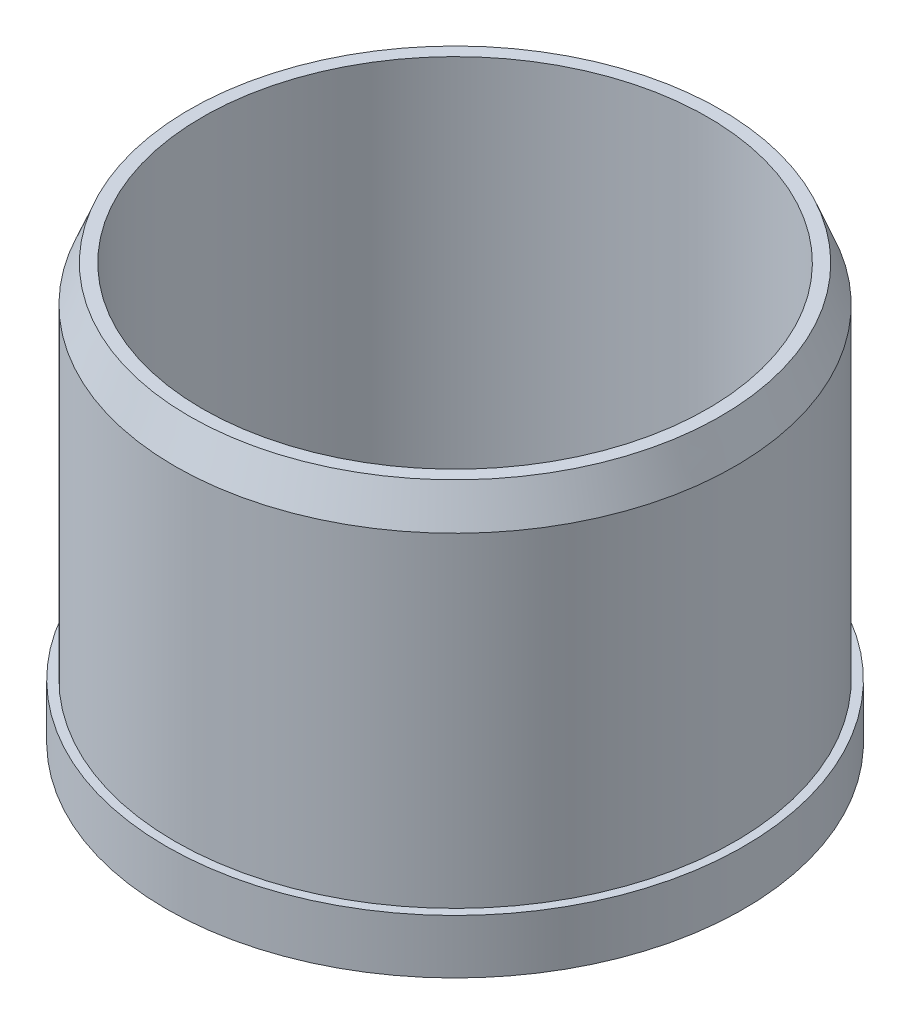
from build123d import *

# Parameters (mm, degrees)
SKETCH1_R           = 50.8
SKETCH1_R_2         = 6.5024
SKETCH1_R_3         = 12.7
BOSS_EXTRUDE1_DEPTH = 9.525
SKETCH2_R           = 49.276
SKETCH2_R_2         = 44.45
BOSS_EXTRUDE2_DEPTH = 63.5
SKETCH3_R           = 12.7
SKETCH3_R_2         = 6.5024
BOSS_EXTRUDE3_DEPTH = 15.875
CHAMFER1_SIZE       = 6.35
CHAMFER1_SIZE2      = 2.54
SKETCH4_R           = 12.7
SKETCH4_R_2         = 6.5024
BOSS_EXTRUDE4_DEPTH = 6.35
FILLET1_R           = 2.54


with BuildPart() as part:
    # Sketch1 → Boss-Extrude1 (new body)
    with BuildSketch(Plane(origin=(0, 0, 0), x_dir=(1, 0, 0), z_dir=(0, 1, 0))):
        Circle(SKETCH1_R)
        Circle(SKETCH1_R_2, mode=Mode.SUBTRACT)
        with Locations((0, 28.575)):
            Circle(SKETCH1_R_3, mode=Mode.SUBTRACT)
        with Locations((27.176439953, 8.830160614)):
            Circle(SKETCH1_R_3, mode=Mode.SUBTRACT)
        with Locations((16.795963584, -23.117660614)):
            Circle(SKETCH1_R_3, mode=Mode.SUBTRACT)
        with Locations((-16.795963584, -23.117660614)):
            Circle(SKETCH1_R_3, mode=Mode.SUBTRACT)
        with Locations((-27.176439953, 8.830160614)):
            Circle(SKETCH1_R_3, mode=Mode.SUBTRACT)
    extrude(amount=BOSS_EXTRUDE1_DEPTH)

    # Sketch2 → Boss-Extrude2 (add)
    with BuildSketch(Plane(origin=(0, 9.525, 0), x_dir=(1, 0, 0), z_dir=(0, 1, 0))):
        Circle(SKETCH2_R)
        Circle(SKETCH2_R_2, mode=Mode.SUBTRACT)
    extrude(amount=BOSS_EXTRUDE2_DEPTH)

    # Sketch3 → Boss-Extrude3 (add)
    with BuildSketch(Plane(origin=(0, 9.525, 0), x_dir=(1, 0, 0), z_dir=(0, 1, 0))):
        Circle(SKETCH3_R)
        Circle(SKETCH3_R_2, mode=Mode.SUBTRACT)
    extrude(amount=BOSS_EXTRUDE3_DEPTH)

    # Chamfer1
    chamfer1_edges = [part.edges().sort_by_distance(p)[0] for p in [
        (-49.276, 73.025, 0),
    ]]
    chamfer1_side = [part.faces().sort_by_distance(p)[0] for p in [
        (-49.276, 41.275, 0),
    ]]
    chamfer(chamfer1_edges, length=CHAMFER1_SIZE, length2=CHAMFER1_SIZE2, reference=chamfer1_side[0])

    # Sketch4 → Boss-Extrude4 (add)
    with BuildSketch(Plane(origin=(0, 25.4, 0), x_dir=(1, 0, 0), z_dir=(0, 1, 0))):
        Circle(SKETCH4_R)
        Circle(SKETCH4_R_2, mode=Mode.SUBTRACT)
    extrude(amount=BOSS_EXTRUDE4_DEPTH)

    # Fillet1
    fillet1_edges = [part.edges().sort_by_distance(p)[0] for p in [
        (-12.7, 31.75, 0),
    ]]
    fillet(fillet1_edges, radius=FILLET1_R)


solid = part.part
